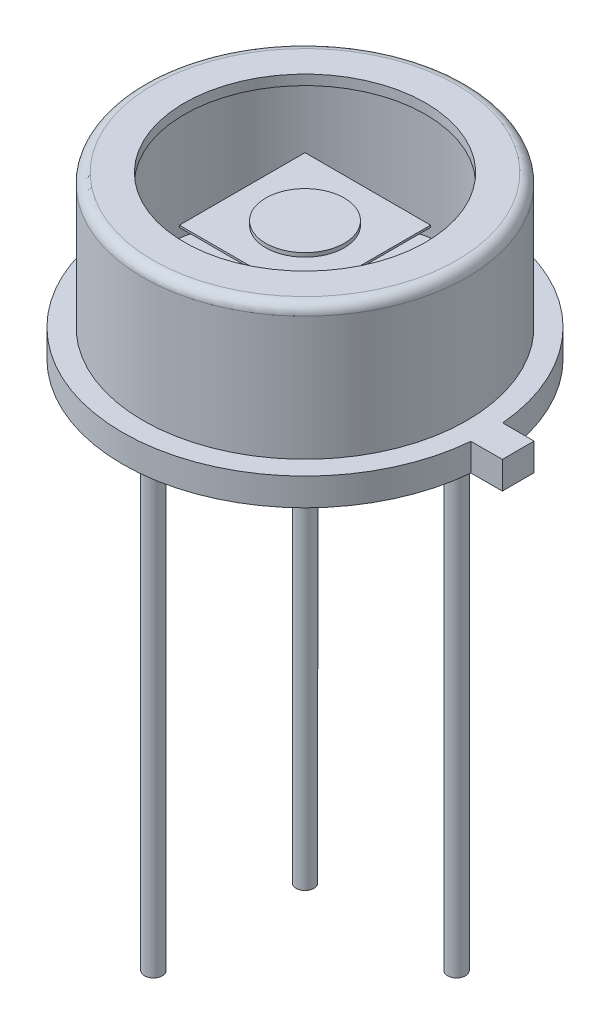
from build123d import *

# Parameters (mm, degrees)
SKETCH2_R           = 4.65
BOSS_EXTRUDE1_DEPTH = 0.446
BOSS_EXTRUDE2_START = -2.95
SKETCH3_W           = 3.2
SKETCH3_H           = 3.2
BOSS_EXTRUDE2_DEPTH = 0.05
SKETCH8_R           = 1
BOSS_EXTRUDE6_DEPTH = 0.1
BOSS_EXTRUDE8_DEPTH = 0.7
SKETCH5_R           = 0.23
BOSS_EXTRUDE4_DEPTH = 13.5


with BuildPart() as part:
    # Sketch1 → Revolve-Thin2 (revolve)
    with BuildSketch(Plane.XY, mode=Mode.PRIVATE) as revolve_thin2_sk:
        with BuildLine():
            Line((4.65, 0), (4.65, 0.7))
            Line((4.65, 0.7), (4.125, 0.7))
            Line((4.125, 0.7), (4.125, 3.856))
            ThreePointArc((4.125, 3.856), (4.050605122, 4.035605122), (3.871, 4.11))
            Line((3.871, 4.11), (3.075, 4.11))
            Line((3.075, 4.11), (3.075, 3.856))
            Line((3.075, 3.856), (3.871, 3.856))
            Line((3.871, 3.856), (3.871, 0.446))
            Line((3.871, 0.446), (4.396, 0.446))
            Line((4.396, 0.446), (4.396, 0))
            Line((4.396, 0), (4.65, 0))
        make_face()
    revolve(revolve_thin2_sk.sketch.rotate(Axis((0, 0, 0), (0, 1, 0)), 90), axis=Axis((0, 0, 0), (0, 1, 0)))  # turned: the seam where the file's is

    # Sketch2 → Boss-Extrude1 (add)
    with BuildSketch(Plane.XZ):
        with Locations(Location((0, 0, 0), (0, 0, 270))):  # turned: the seam where the file's is
            Circle(SKETCH2_R)
    extrude(amount=-BOSS_EXTRUDE1_DEPTH)

    # Sketch11 → Boss-Extrude8 (add)
    with BuildSketch(Plane.XZ):
        with BuildLine():
            Line((5.432329328, -0.405), (5.432329328, 0))
            Line((5.432329328, 0), (5.432329328, 0.405))
            Line((5.432329328, 0.405), (4.632329328, 0.405))
            ThreePointArc((4.632329328, 0.405), (4.645580231, 0.202692657), (4.65, 0))
            ThreePointArc((4.65, 0), (4.645580231, -0.202692657), (4.632329328, -0.405))
            Line((4.632329328, -0.405), (5.432329328, -0.405))
        make_face()
    extrude(amount=-BOSS_EXTRUDE8_DEPTH)

    # Sketch5 → Boss-Extrude4 (add)
    with BuildSketch(Plane.XZ):
        with Locations(Location((1.930401513, -1.930401513, 0), (0, 0, 90))):  # turned: the seam where the file's is
            Circle(SKETCH5_R)
        with Locations(Location((-1.930401513, 1.930401513, 0), (0, 0, 90))):  # turned: the seam where the file's is
            Circle(SKETCH5_R)
        with Locations(Location((-1.930401513, -1.930401513, 0), (0, 0, 90))):  # turned: the seam where the file's is
            Circle(SKETCH5_R)
    extrude(amount=BOSS_EXTRUDE4_DEPTH)


with BuildPart() as body_2:
    # Sketch3 → Boss-Extrude2 (new body)
    with BuildSketch(Plane.XZ.offset(BOSS_EXTRUDE2_START)):
        Rectangle(SKETCH3_W, SKETCH3_H)
    extrude(amount=BOSS_EXTRUDE2_DEPTH)

    # Sketch8 → Boss-Extrude6 (add)
    with BuildSketch(Plane(origin=(0, 2.95, 0), x_dir=(-1, 0, 0), z_dir=(0, 1, 0))):
        with Locations(Location((0, 0, 0), (0, 0, 270))):  # turned: the seam where the file's is
            Circle(SKETCH8_R)
    extrude(amount=BOSS_EXTRUDE6_DEPTH)


solid = Compound([part.part, body_2.part])
